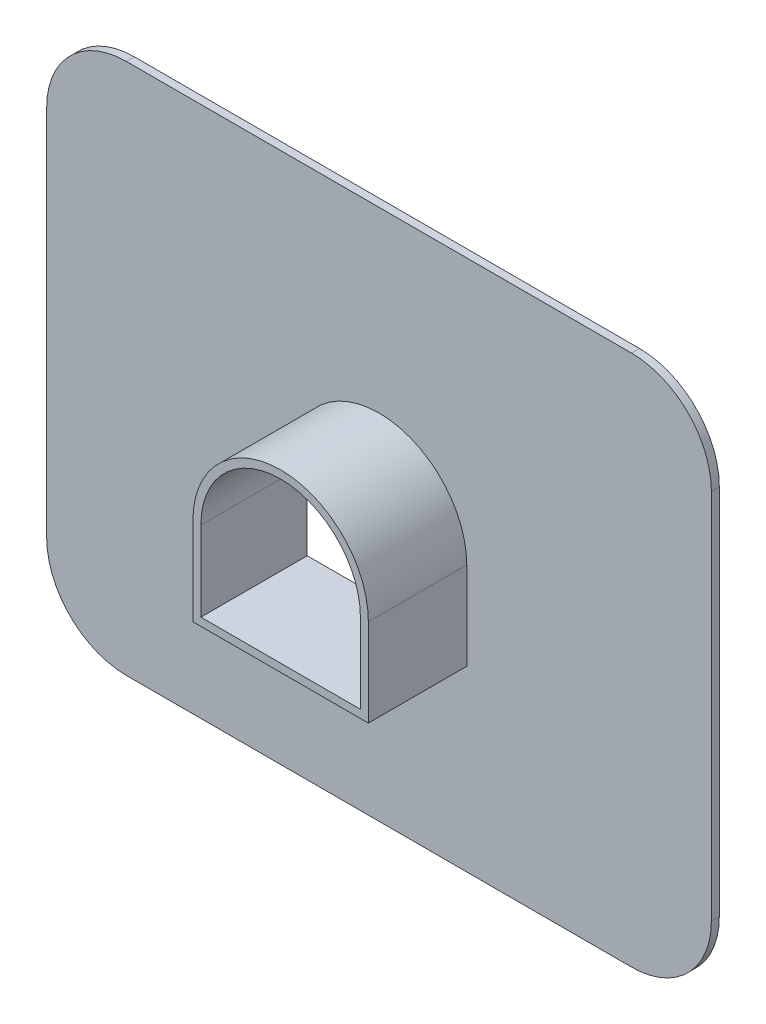
from build123d import *

# Parameters (mm, degrees)
EXTRUSION1_DEPTH = 0.3
EXTRUSION2_DEPTH = 3.7


with BuildPart() as part:
    # Esquisse1 → Extrusion1 (new body)
    with BuildSketch(Plane.XY):
        with BuildLine():
            Line((-9.5, 10), (9.5, 10))
            ThreePointArc((9.5, 10), (11.621320344, 9.121320344), (12.5, 7))
            Line((12.5, 7), (12.5, -7))
            ThreePointArc((12.5, -7), (11.621320344, -9.121320344), (9.5, -10))
            Line((9.5, -10), (-9.5, -10))
            ThreePointArc((-9.5, -10), (-11.621320344, -9.121320344), (-12.5, -7))
            Line((-12.5, -7), (-12.5, 7))
            ThreePointArc((-12.5, 7), (-11.621320344, 9.121320344), (-9.5, 10))
        make_face()
        with BuildLine():
            Line((-3, -3), (3, -3))
            Line((3, -3), (3, 0))
            ThreePointArc((3, 0), (0, 3), (-3, 0))
            Line((-3, 0), (-3, -3))
        make_face(mode=Mode.SUBTRACT)
    extrude(amount=EXTRUSION1_DEPTH)

    # Esquisse2 → Extrusion2 (add)
    with BuildSketch(Plane.XY.offset(0.3)):
        with BuildLine():
            Line((-3.3, -3.3), (3.3, -3.3))
            Line((3.3, -3.3), (3.3, 0))
            ThreePointArc((3.3, 0), (0, 3.3), (-3.3, 0))
            Line((-3.3, 0), (-3.3, -3.3))
        make_face()
        with BuildLine():
            Line((-3, -3), (3, -3))
            Line((3, -3), (3, 0))
            ThreePointArc((3, 0), (0, 3), (-3, 0))
            Line((-3, 0), (-3, -3))
        make_face(mode=Mode.SUBTRACT)
    extrude(amount=EXTRUSION2_DEPTH)


solid = part.part
